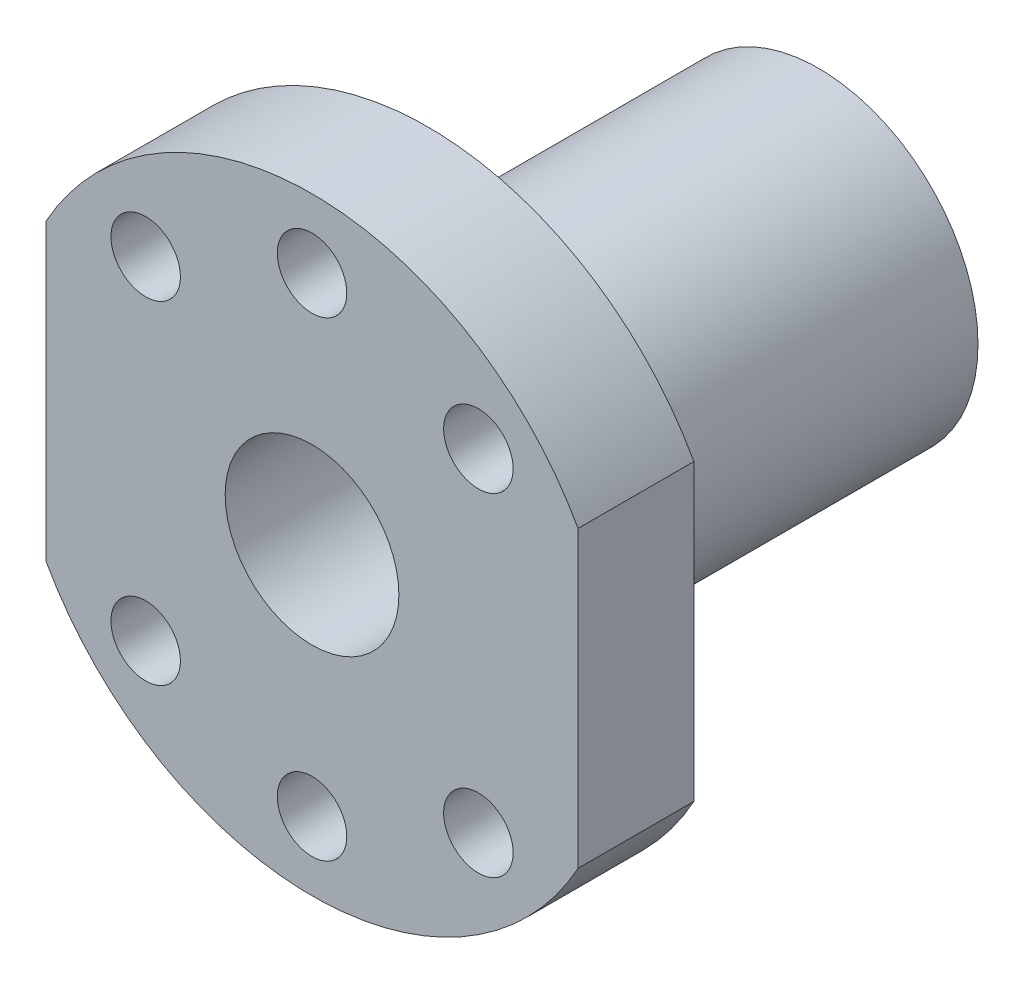
from build123d import *

# Parameters (mm, degrees)
SKETCH1_R           = 6
BOSS_EXTRUDE1_DEPTH = 4
SKETCH2_R           = 2.4
CUT_EXTRUDE1_DEPTH  = 9
SKETCH3_R           = 11
SKETCH3_R_2         = 6
BOSS_EXTRUDE2_DEPTH = 27


with BuildPart() as part:
    # Sketch1 → Boss-Extrude1 (new body, symmetric)
    with BuildSketch(Plane.XY):
        with BuildLine():
            Line((-18.375, 10.166581284), (-18.375, -10.166581284))
            ThreePointArc((-18.375, -10.166581284), (0, -21), (18.375, -10.166581284))
            Line((18.375, -10.166581284), (18.375, 10.166581284))
            ThreePointArc((18.375, 10.166581284), (0, 21), (-18.375, 10.166581284))
        make_face()
        Circle(SKETCH1_R, mode=Mode.SUBTRACT)
    extrude(amount=BOSS_EXTRUDE1_DEPTH, both=True)

    # Sketch2 → Cut-Extrude1 (cut, through all)
    with BuildSketch(Plane.XY.offset(4)):
        with Locations((-11.490485194, 11.490485194)):
            Circle(SKETCH2_R)
        with Locations((0, 16.25)):
            Circle(SKETCH2_R)
        with Locations((11.490485194, 11.490485194)):
            Circle(SKETCH2_R)
        with Locations((11.490485194, -11.490485194)):
            Circle(SKETCH2_R)
        with Locations((0, -16.25)):
            Circle(SKETCH2_R)
        with Locations((-11.490485194, -11.490485194)):
            Circle(SKETCH2_R)
    extrude(amount=-CUT_EXTRUDE1_DEPTH, mode=Mode.SUBTRACT)

    # Sketch3 → Boss-Extrude2 (add)
    with BuildSketch(Plane(origin=(0, 0, -4), x_dir=(-1, 0, 0), z_dir=(0, 0, -1))):
        Circle(SKETCH3_R)
        Circle(SKETCH3_R_2, mode=Mode.SUBTRACT)
    extrude(amount=BOSS_EXTRUDE2_DEPTH)


solid = part.part
